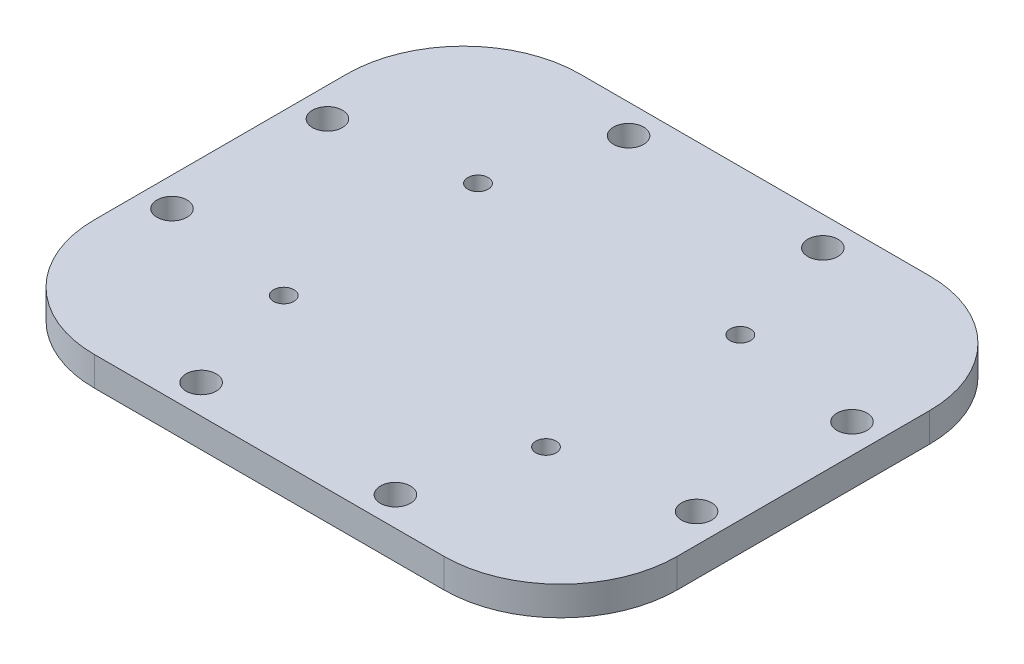
from build123d import *

# Parameters (mm, degrees)
SKETCH_1_W          = 60
SKETCH_1_H          = 50
EXTRUDE_1_DEPTH     = 3
SKETCH_7_R          = 1.05
CUT_EXTRUDE_1_DEPTH = 10
SKETCH_8_R          = 1.55
CUT_EXTRUDE_2_DEPTH = 10
FILLET_1_R          = 12


with BuildPart() as part:
    # 草图1 → 凸台-拉伸1 (new body)
    with BuildSketch(Plane(origin=(0, 0, 0), x_dir=(1, 0, 0), z_dir=(0, 1, 0))):
        Rectangle(SKETCH_1_W, SKETCH_1_H)
    extrude(amount=EXTRUDE_1_DEPTH)

    # 草图7 → 切除-拉伸1 (cut)
    with BuildSketch(Plane(origin=(0, 3, 0), x_dir=(1, 0, 0), z_dir=(0, 1, 0))):
        with Locations((13.5, 10)):
            Circle(SKETCH_7_R)
        with Locations((-13.5, 10)):
            Circle(SKETCH_7_R)
        with Locations((-13.5, -10)):
            Circle(SKETCH_7_R)
        with Locations((13.5, -10)):
            Circle(SKETCH_7_R)
    extrude(amount=-CUT_EXTRUDE_1_DEPTH, mode=Mode.SUBTRACT)

    # 草图8 → 切除-拉伸2 (cut)
    with BuildSketch(Plane.XZ):
        with Locations((27, 8)):
            Circle(SKETCH_8_R)
        with Locations((10, 22)):
            Circle(SKETCH_8_R)
        with Locations((-10, 22)):
            Circle(SKETCH_8_R)
        with Locations((-27, 8)):
            Circle(SKETCH_8_R)
        with Locations((-27, -8)):
            Circle(SKETCH_8_R)
        with Locations((-10, -22)):
            Circle(SKETCH_8_R)
        with Locations((10, -22)):
            Circle(SKETCH_8_R)
        with Locations((27, -8)):
            Circle(SKETCH_8_R)
    extrude(amount=-CUT_EXTRUDE_2_DEPTH, mode=Mode.SUBTRACT)

    # 圆角1
    fillet_1_edges = [part.edges().sort_by_distance(p)[0] for p in [
        (30, 1.5, 25),
        (-30, 1.5, 25),
        (-30, 1.5, -25),
        (30, 1.5, -25),
    ]]
    fillet(fillet_1_edges, radius=FILLET_1_R)


solid = part.part
